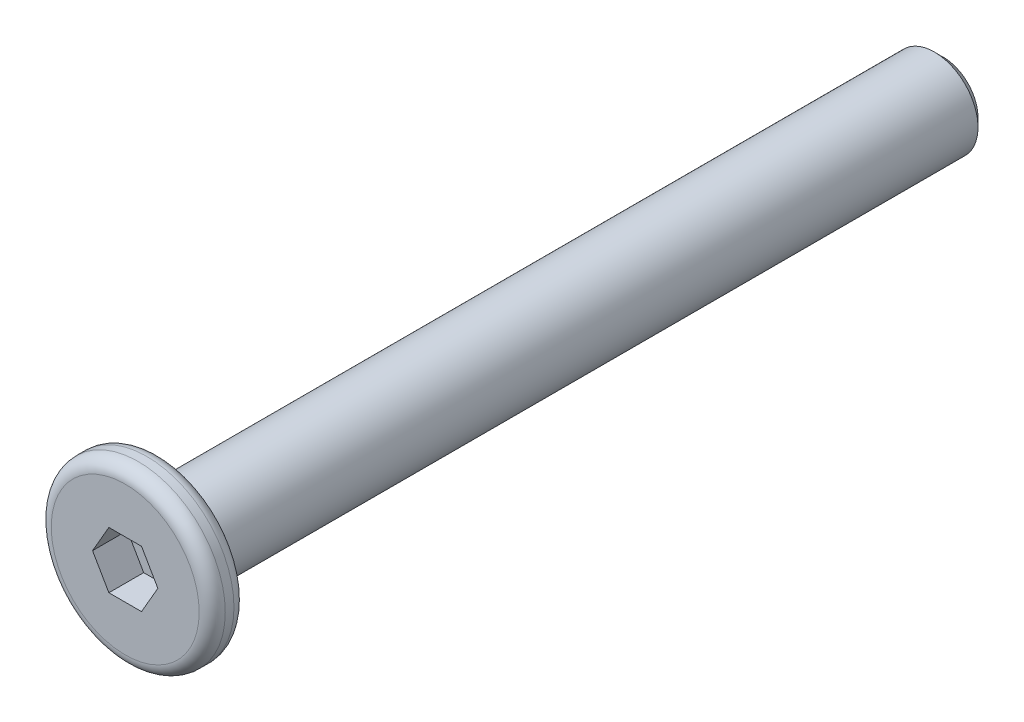
from build123d import *

# Parameters (mm, degrees)
SKETCH_1_R          = 2
EXTRUDE_1_DEPTH     = 0.4
SKETCH_2_R          = 1
EXTRUDE_2_DEPTH     = 18
CHAMFER_1_SIZE      = 0.2
CUT_EXTRUDE_1_DEPTH = 0.8
FILLET_2_R          = 0.3


with BuildPart() as part:
    # 草图1 → 凸台-拉伸1 (new body, symmetric)
    with BuildSketch(Plane.XY):
        Circle(SKETCH_1_R)
    extrude(amount=EXTRUDE_1_DEPTH, both=True)

    # 草图2 → 凸台-拉伸2 (add)
    with BuildSketch(Plane(origin=(0, 0, -0.4), x_dir=(-1, 0, 0), z_dir=(0, 0, -1))):
        Circle(SKETCH_2_R)
    extrude(amount=EXTRUDE_2_DEPTH)

    # 倒角1
    chamfer_1_edges = [part.edges().sort_by_distance(p)[0] for p in [
        (1, 0, -18.4),
    ]]
    chamfer(chamfer_1_edges, length=CHAMFER_1_SIZE)

    # 草图3 → 切除-拉伸1 (cut)
    with BuildSketch(Plane.XY.offset(0.4)):
        Polygon((0.75055535, 0), (0.375277675, 0.65), (-0.375277675, 0.65), (-0.75055535, 0), (-0.375277675, -0.65), (0.375277675, -0.65), align=None)
    extrude(amount=-CUT_EXTRUDE_1_DEPTH, mode=Mode.SUBTRACT)

    # 圆角2
    fillet_2_edges = [part.edges().sort_by_distance(p)[0] for p in [
        (-2, 0, -0.4),
        (-2, 0, 0.4),
    ]]
    fillet(fillet_2_edges, radius=FILLET_2_R)


solid = part.part
